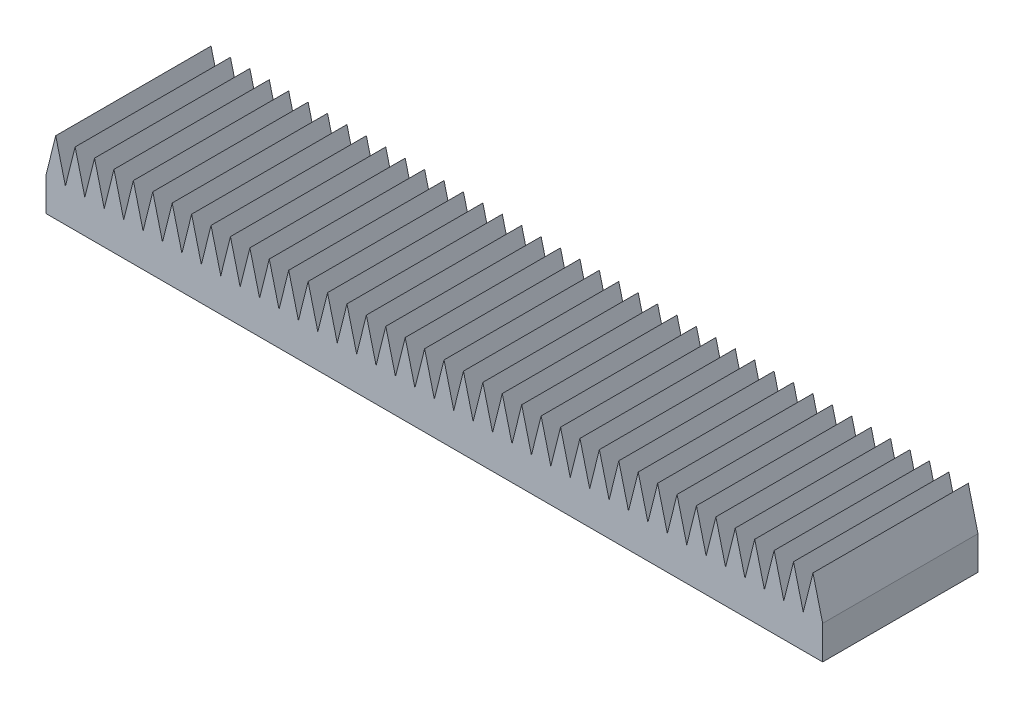
from build123d import *

# Parameters (mm, degrees)
BOSS_EXTRUDE1_DEPTH = 40


with BuildPart() as part:
    # Sketch1 → Boss-Extrude1 (new body)
    with BuildSketch(Plane.XY):
        Polygon((-100, 4.308297624), (-97.5, 14.308297624), (-95, 4.308297624), (-92.5, 14.308297624), (-90, 4.308297624), (-87.5, 14.308297624), (-85, 4.308297624), (-82.5, 14.308297624), (-80, 4.308297624), (-77.5, 14.308297624), (-75, 4.308297624), (-72.5, 14.308297624), (-70, 4.308297624), (-67.5, 14.308297624), (-65, 4.308297624), (-62.5, 14.308297624), (-60, 4.308297624), (-57.5, 14.308297624), (-55, 4.308297624), (-52.5, 14.308297624), (-50, 4.308297624), (-47.5, 14.308297624), (-45, 4.308297624), (-42.5, 14.308297624), (-40, 4.308297624), (-37.5, 14.308297624), (-35, 4.308297624), (-32.5, 14.308297624), (-30, 4.308297624), (-27.5, 14.308297624), (-25, 4.308297624), (-22.5, 14.308297624), (-20, 4.308297624), (-17.5, 14.308297624), (-15, 4.308297624), (-12.5, 14.308297624), (-10, 4.308297624), (-7.5, 14.308297624), (-5, 4.308297624), (-2.5, 14.308297624), (0, 4.308297624), (2.5, 14.308297624), (5, 4.308297624), (7.5, 14.308297624), (10, 4.308297624), (12.5, 14.308297624), (15, 4.308297624), (17.5, 14.308297624), (20, 4.308297624), (22.5, 14.308297624), (25, 4.308297624), (27.5, 14.308297624), (30, 4.308297624), (32.5, 14.308297624), (35, 4.308297624), (37.5, 14.308297624), (40, 4.308297624), (42.5, 14.308297624), (45, 4.308297624), (47.5, 14.308297624), (50, 4.308297624), (52.5, 14.308297624), (55, 4.308297624), (57.5, 14.308297624), (60, 4.308297624), (62.5, 14.308297624), (65, 4.308297624), (67.5, 14.308297624), (70, 4.308297624), (72.5, 14.308297624), (75, 4.308297624), (77.5, 14.308297624), (80, 4.308297624), (82.5, 14.308297624), (85, 4.308297624), (87.5, 14.308297624), (90, 4.308297624), (92.5, 14.308297624), (95, 4.308297624), (97.5, 14.308297624), (100, 4.308297624), (100, -4.308297624), (-100, -4.308297624), align=None)
    extrude(amount=BOSS_EXTRUDE1_DEPTH)


solid = part.part
